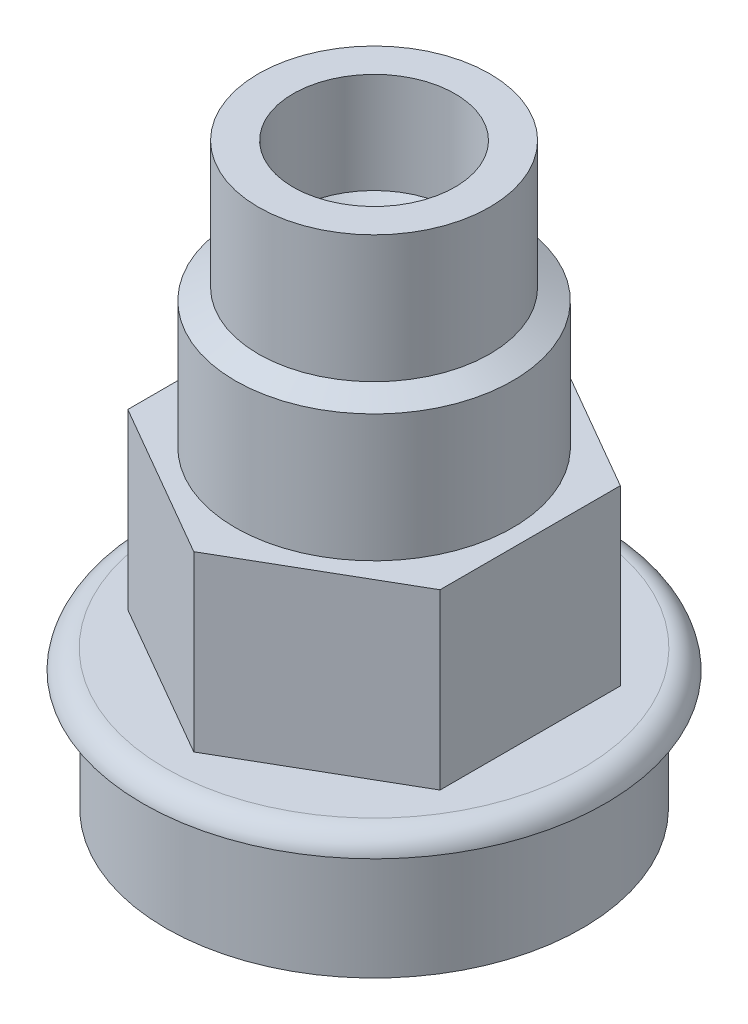
from build123d import *

# Parameters (mm, degrees)
SKETCH2_R           = 9
BOSS_EXTRUDE2_DEPTH = 15


with BuildPart() as part:
    # Sketch1 → Revolve1 (revolve)
    with BuildSketch(Plane(origin=(0, 0, 0), x_dir=(0, 0, -1), z_dir=(1, 0, 0))):
        with BuildLine():
            Line((13, -24), (13, -13))
            Line((13, -13), (18.02920611, -13))
            ThreePointArc((18.02920611, -13), (19.317404153, -13.470115755), (20, -14.659454198))
            Line((20, -14.659454198), (18, -14.659454198))
            Line((18, -14.659454198), (18, -25))
            Line((18, -25), (14.151715331, -25))
            Line((14.151715331, -25), (13, -24))
        make_face()
        Polygon((10, 25), (7, 25), (7, 16.3), (6, 15.3), (6, 10), (7, 10), (7, 2), (12, 2), (12, 13), (10, 14), align=None)
    revolve(axis=Axis((0, 25, 0), (0, -1, 0)))

    # Sketch2 → Boss-Extrude2 (add)
    with BuildSketch(Plane(origin=(0, -13, 0), x_dir=(1, 0, 0), z_dir=(0, 1, 0))):
        Polygon((0, 15.588457268), (-13.5, 7.794228634), (-13.5, -7.794228634), (0, -15.588457268), (13.5, -7.794228634), (13.5, 7.794228634), align=None)
        Circle(SKETCH2_R, mode=Mode.SUBTRACT)
    extrude(amount=BOSS_EXTRUDE2_DEPTH)


solid = part.part
